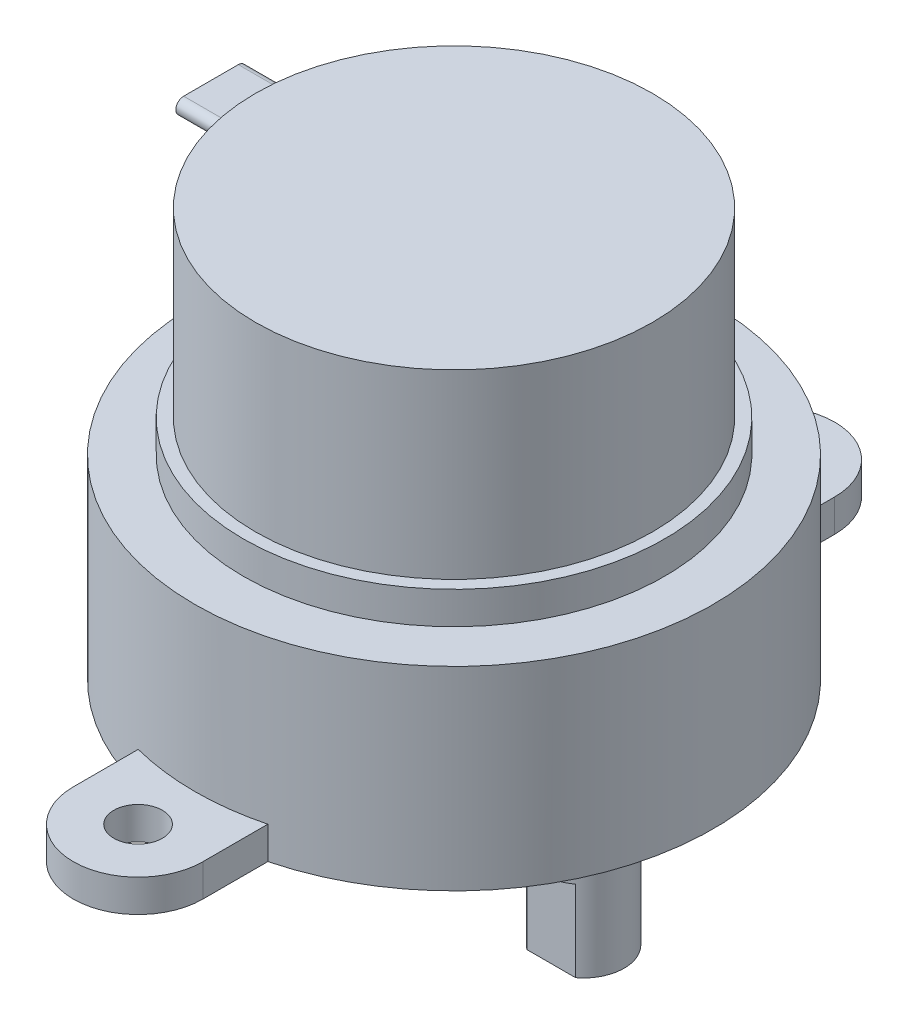
from build123d import *

# Parameters (mm, degrees)
HOLE_WIZARD_M4_1_D     = 3.3
HOLE_WIZARD_M4_1_DEPTH = 7.5
HOLE_WIZARD_M4_1_TIP   = 0.991420021
CUT_EXTRUDE_START      = 10.2
SKETCH_5_W             = 10.320177725
SKETCH_5_H             = 3.570001837
SKETCH_5_W_2           = 11.817937116
SKETCH_5_H_2           = 2.503104736
CUT_EXTRUDE_1_DEPTH    = 5
SKETCH_6_R             = 1.5
EXTRUDE_1_DEPTH        = 2
EXTRUDE_2_DEPTH        = 15


with BuildPart() as part:
    # 草图1 → 旋转1 (revolve)
    with BuildSketch(Plane.XY):
        Polygon((0, 0), (-16, 0), (-16, 12), (-13, 12), (-13, 14), (-12.25, 14), (-12.25, 25.2), (0, 25.2), align=None)
    revolve(axis=Axis((0, 25.2, 0), (0, -1, 0)))

    # 草图2 → 旋转2 (revolve)
    with BuildSketch(Plane.XY):
        Polygon((8, -10.2), (5.5, -10.2), (5.5, -2.7), (4, -2.7), (4, -1.25), (3.5, -1.25), (3.5, 0), (8, 0), align=None)
    revolve(axis=Axis((8, 0, 0), (0, -1, 0)))

    # M4 螺纹孔1
    with Locations(Plane(origin=(0, -10.2, 0), x_dir=(-1, 0, 0), z_dir=(0, -1, 0))):
        with Locations((-8, 0)):
            Hole(HOLE_WIZARD_M4_1_D / 2, depth=HOLE_WIZARD_M4_1_DEPTH)
            with Locations((0, 0, -(HOLE_WIZARD_M4_1_DEPTH + HOLE_WIZARD_M4_1_TIP / 2))):  # 118° drill point
                Cone(0, HOLE_WIZARD_M4_1_D / 2, HOLE_WIZARD_M4_1_TIP, mode=Mode.SUBTRACT)

    # 草图5 → 切除-拉伸1 (cut)
    with BuildSketch(Plane.XZ.offset(CUT_EXTRUDE_START)):
        with Locations((7.585780696, 3.785000919)):
            Rectangle(SKETCH_5_W, SKETCH_5_H)
        with Locations((6.836901, -3.251552368)):
            Rectangle(SKETCH_5_W_2, SKETCH_5_H_2)
    extrude(amount=-CUT_EXTRUDE_1_DEPTH, mode=Mode.SUBTRACT)

    # 草图6 → 凸台-拉伸1 (add)
    with BuildSketch(Plane.XZ):
        with BuildLine():
            Line((4, 19.5), (4, -19.5))
            ThreePointArc((4, -19.5), (0, -23.5), (-4, -19.5))
            Line((-4, -19.5), (-4, 19.5))
            ThreePointArc((-4, 19.5), (0, 23.5), (4, 19.5))
        make_face()
        with Locations((0, -19.5)):
            Circle(SKETCH_6_R, mode=Mode.SUBTRACT)
        with Locations((0, 19.5)):
            Circle(SKETCH_6_R, mode=Mode.SUBTRACT)
    extrude(amount=-EXTRUDE_1_DEPTH)

    # 草图7 → 凸台-拉伸2 (add)
    with BuildSketch(Plane(origin=(0, 0, 0), x_dir=(0, 0, -1), z_dir=(1, 0, 0))):
        with BuildLine():
            Line((-1.687384392, 24.513955372), (1.687384392, 24.513955372))
            ThreePointArc((1.687384392, 24.513955372), (2.169302813, 24.032036951), (1.687384392, 23.550118529))
            Line((1.687384392, 23.550118529), (-1.687384392, 23.550118529))
            ThreePointArc((-1.687384392, 23.550118529), (-2.169302813, 24.032036951), (-1.687384392, 24.513955372))
        make_face()
    extrude(amount=-EXTRUDE_2_DEPTH)


solid = part.part
